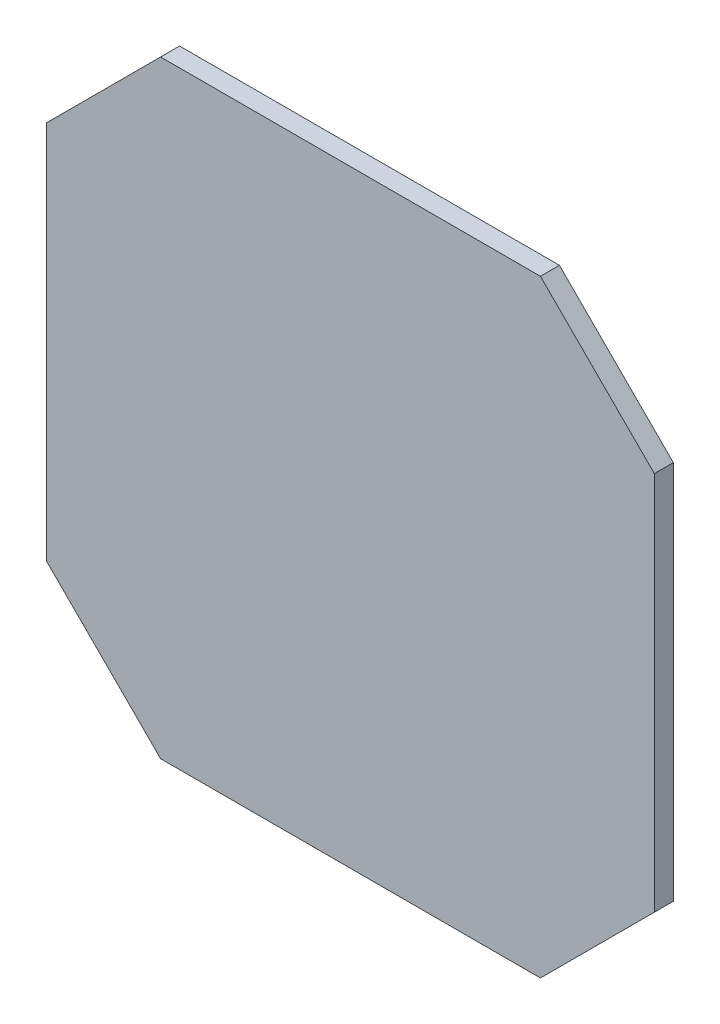
from build123d import *

# Parameters (mm, degrees)
BOSS_EXTRUDE1_DEPTH = 5


with BuildPart() as part:
    # Sketch1 → Boss-Extrude1 (new body)
    with BuildSketch(Plane.XY):
        Polygon((-80, -50), (-50, -80), (50, -80), (80, -50), (80, 50), (50, 80), (-50, 80), (-80, 50), align=None)
    extrude(amount=BOSS_EXTRUDE1_DEPTH)


solid = part.part
